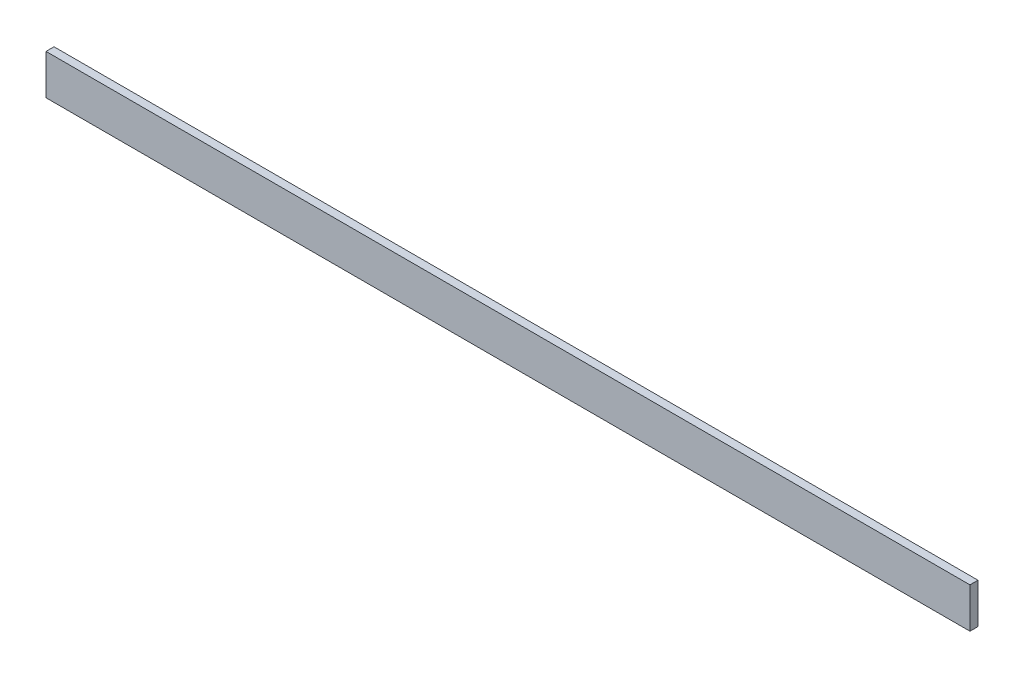
from build123d import *

# Parameters (mm, degrees)
SKETCH_1_W      = 460
SKETCH_1_H      = 20
EXTRUDE_1_DEPTH = 4


with BuildPart() as part:
    # Эскиз1 → Бобышка-Вытянуть1 (new body)
    with BuildSketch(Plane.XY):
        with Locations((230, 10)):
            Rectangle(SKETCH_1_W, SKETCH_1_H)
    extrude(amount=EXTRUDE_1_DEPTH)


solid = part.part
